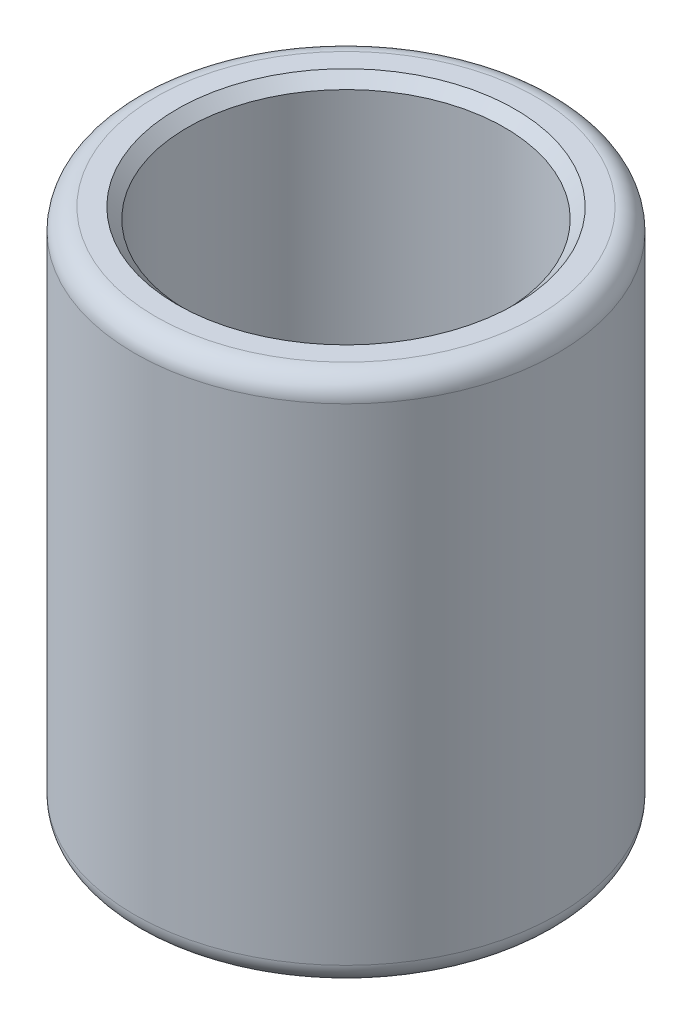
from build123d import *

# Parameters (mm, degrees)
ESBO_O1_R                = 20
ESBO_O1_R_2              = 15
RESSALTO_EXTRUS_O1_DEPTH = 50
FILETE1_R                = 2
CHANFRO1_SIZE            = 1


with BuildPart() as part:
    # Esboço1 → Ressalto-extrusão1 (new body)
    with BuildSketch(Plane(origin=(0, 0, 0), x_dir=(1, 0, 0), z_dir=(0, 1, 0))):
        with Locations(Location((0, 0, 0), (0, 0, 270))):  # turned: the seam where the file's is
            Circle(ESBO_O1_R)
        with Locations(Location((0, 0, 0), (0, 0, 270))):  # turned: the seam where the file's is
            Circle(ESBO_O1_R_2, mode=Mode.SUBTRACT)
    extrude(amount=RESSALTO_EXTRUS_O1_DEPTH)

    # Filete1
    filete1_edges = [part.edges().sort_by_distance(p)[0] for p in [
        (0, 0, -20),
        (0, 50, -20),
    ]]
    fillet(filete1_edges, radius=FILETE1_R)

    # Chanfro1
    chanfro1_edges = [part.edges().sort_by_distance(p)[0] for p in [
        (0, 0, -15),
        (0, 50, -15),
    ]]
    chamfer(chanfro1_edges, length=CHANFRO1_SIZE)


solid = part.part
